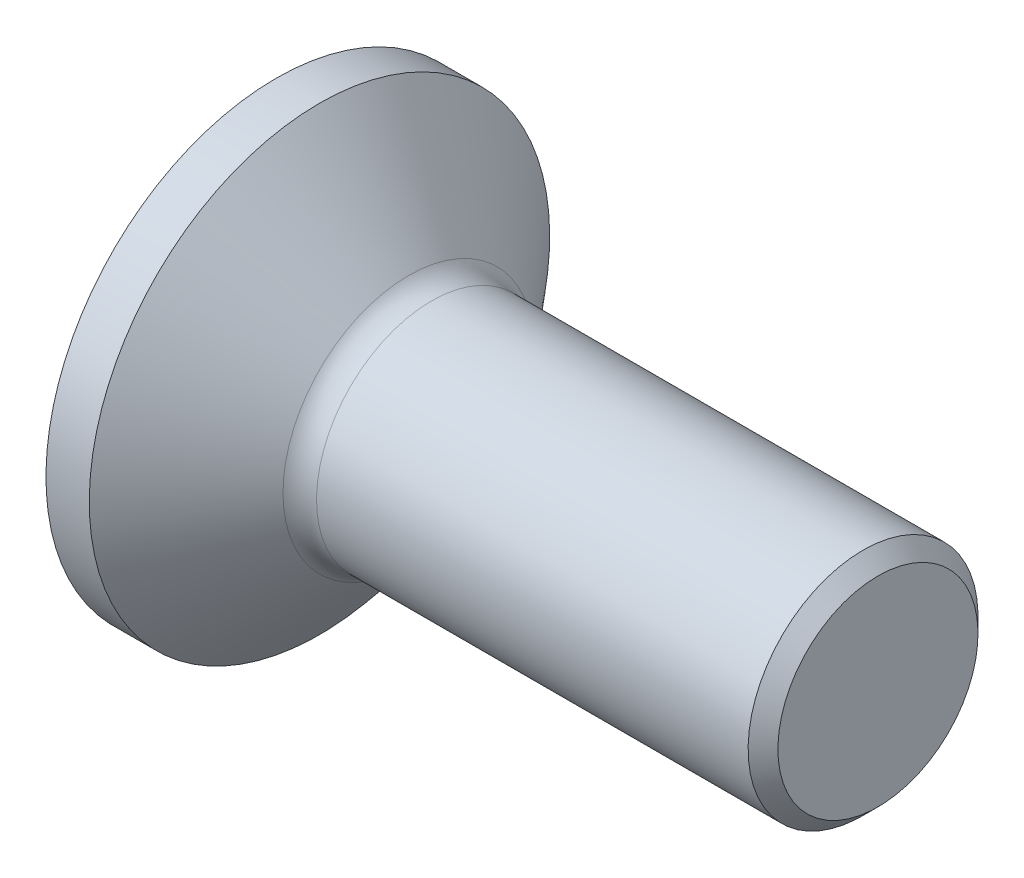
from build123d import *

# Parameters (mm, degrees)
CUT_EXTRUDE1_DEPTH = 1.5


with BuildPart() as part:
    # Sketch1 → Revolve1 (revolve)
    with BuildSketch(Plane.XY):
        with BuildLine():
            Line((2.580774618, 1.91), (9.752512627, 1.91))
            Line((9.752512627, 1.91), (10, 1.662512627))
            Line((10, 1.662512627), (10, 0))
            Line((10, 0), (0, 0))
            Line((0, 0), (0, 3.825))
            Line((0, 3.825), (0.72, 3.825))
            Line((0.72, 3.825), (2.2, 2.08594647))
            ThreePointArc((2.2, 2.08594647), (2.37104475, 1.956113029), (2.580774618, 1.91))
        make_face()
    revolve(axis=Axis((0, 0, 0), (-1, 0, 0)))

    # Sketch2 → Cut-Extrude1 (cut)
    with BuildSketch(Plane.ZY):
        Polygon((1.25, 0.721687836), (0, 1.443375673), (-1.25, 0.721687836), (-1.25, -0.721687836), (0, -1.443375673), (1.25, -0.721687836), align=None)
    extrude(amount=-CUT_EXTRUDE1_DEPTH, mode=Mode.SUBTRACT)


solid = part.part
